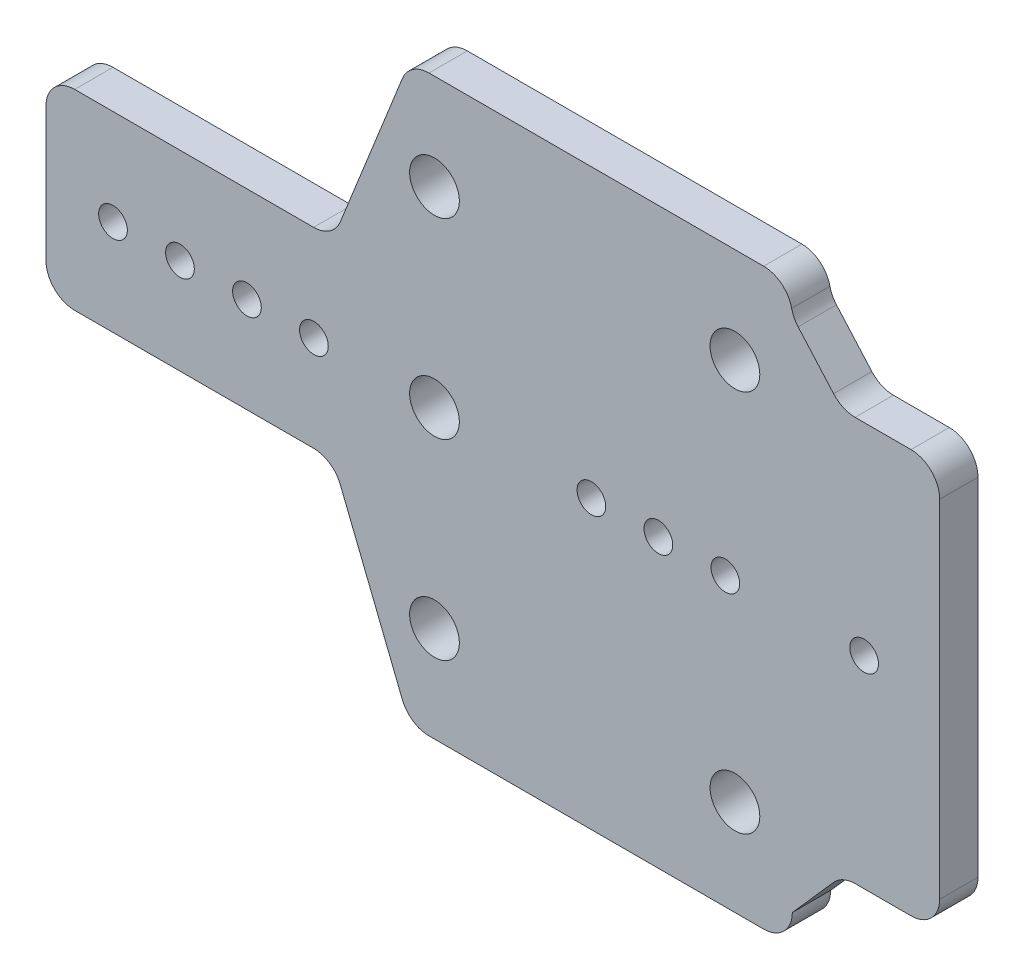
from build123d import *

# Parameters (mm, degrees)
BOSS_EXTRUDE1_DEPTH = 4
FILLET1_R           = 3
SKETCH3_R           = 2.6
CUT_EXTRUDE1_DEPTH  = 4
SKETCH4_R           = 1.5
CUT_EXTRUDE2_DEPTH  = 4
SKETCH5_W           = 15
SKETCH5_H           = 20
BOSS_EXTRUDE2_DEPTH = 4
BOSS_EXTRUDE3_DEPTH = 4
SKETCH7_R           = 1.5
CUT_EXTRUDE3_DEPTH  = 4
BOSS_EXTRUDE4_DEPTH = 4
SKETCH10_R          = 11.5
CUT_EXTRUDE4_DEPTH  = 4
SKETCH14_R          = 1.5
CUT_EXTRUDE5_DEPTH  = 4
FILLET2_R           = 3
SKETCH17_W          = 41.796836064
SKETCH17_H          = 42.2
CUT_EXTRUDE6_DEPTH  = 10
FILLET3_R           = 3


with BuildPart() as part:
    # Sketch1 → Boss-Extrude1 (new body)
    with BuildSketch(Plane.XY):
        Polygon((39, 10), (39, 30), (-1, 30), (-9, 10), (-39, 10), (-39, -10), (-9, -10), (-1, -30), (39, -30), (39, -10), align=None)
    extrude(amount=BOSS_EXTRUDE1_DEPTH)

    # Fillet1
    fillet1_edges = [part.edges().sort_by_distance(p)[0] for p in [
        (39, -30, 2),
        (-1, -30, 2),
        (-9, -10, 2),
        (-39, -10, 2),
        (-39, 10, 2),
        (-9, 10, 2),
        (-1, 30, 2),
        (39, 30, 2),
    ]]
    fillet(fillet1_edges, radius=FILLET1_R)

    # Sketch3 → Cut-Extrude1 (cut)
    with BuildSketch(Plane.XY.offset(4)):
        with Locations((33, 20)):
            Circle(SKETCH3_R)
        with Locations((1.6, 20)):
            Circle(SKETCH3_R)
        with Locations((33, -20)):
            Circle(SKETCH3_R)
        with Locations((1.6, -20)):
            Circle(SKETCH3_R)
        with Locations((1.6, 0)):
            Circle(SKETCH3_R)
    extrude(amount=-CUT_EXTRUDE1_DEPTH, mode=Mode.SUBTRACT)

    # Sketch4 → Cut-Extrude2 (cut)
    with BuildSketch(Plane.XY.offset(4)):
        with Locations((-32, 0)):
            Circle(SKETCH4_R)
        with Locations((-25, 0)):
            Circle(SKETCH4_R)
        with Locations((-18, 0)):
            Circle(SKETCH4_R)
        with Locations((-11, 0)):
            Circle(SKETCH4_R)
        with Locations((32, 0)):
            Circle(SKETCH4_R)
        with Locations((25, 0)):
            Circle(SKETCH4_R)
        with Locations((18, 0)):
            Circle(SKETCH4_R)
    extrude(amount=-CUT_EXTRUDE2_DEPTH, mode=Mode.SUBTRACT)

    # Sketch5 → Boss-Extrude2 (add)
    with BuildSketch(Plane.XY.offset(4)):
        with Locations((46.5, 0)):
            Rectangle(SKETCH5_W, SKETCH5_H)
    extrude(amount=-BOSS_EXTRUDE2_DEPTH)

    # Sketch6 → Boss-Extrude3 (add)
    with BuildSketch(Plane.XY.offset(4)):
        Polygon((39, 10), (54, 10), (39, 27), align=None)
        Polygon((54, -10), (39, -10), (39, -27), align=None)
    extrude(amount=-BOSS_EXTRUDE3_DEPTH)

    # Sketch7 → Cut-Extrude3 (cut)
    with BuildSketch(Plane.XY.offset(4)):
        with Locations((46.5, 0)):
            Circle(SKETCH7_R)
    extrude(amount=-CUT_EXTRUDE3_DEPTH, mode=Mode.SUBTRACT)

    # Sketch8 → Boss-Extrude4 (add)
    with BuildSketch(Plane.XY.offset(4)):
        Polygon((54, -10), (54, -21.1), (96.2, -21.1), (96.2, 21.1), (54, 21.1), (54, 10), align=None)
        Polygon((44.205882353, 21.1), (54, 10), (54, 21.1), align=None)
        Polygon((44.205882353, -21.1), (54, -21.1), (54, -10), align=None)
    extrude(amount=-BOSS_EXTRUDE4_DEPTH)

    # Sketch10 → Cut-Extrude4 (cut)
    with BuildSketch(Plane.XY.offset(4)):
        with Locations((74.8, 0)):
            Circle(SKETCH10_R)
    extrude(amount=-CUT_EXTRUDE4_DEPTH, mode=Mode.SUBTRACT)

    # Sketch14 → Cut-Extrude5 (cut)
    with BuildSketch(Plane.XY.offset(4)):
        with Locations((90.674547238, 15.874547238)):
            Circle(SKETCH14_R)
        with Locations((58.925452762, -15.874547238)):
            Circle(SKETCH14_R)
        with Locations((58.925452762, 15.874547238)):
            Circle(SKETCH14_R)
        with Locations((90.674547238, -15.874547238)):
            Circle(SKETCH14_R)
    extrude(amount=-CUT_EXTRUDE5_DEPTH, mode=Mode.SUBTRACT)

    # Fillet2
    fillet2_edges = [part.edges().sort_by_distance(p)[0] for p in [
        (96.2, -21.1, 2),
        (44.205882353, -21.1, 2),
        (44.205882353, 21.1, 2),
        (96.2, 21.1, 2),
        (39, 27, 2),
    ]]
    fillet(fillet2_edges, radius=FILLET2_R)

    # Sketch17 → Cut-Extrude6 (cut)
    with BuildSketch(Plane.XY.offset(4)):
        with Locations((75.301581968, 0)):
            Rectangle(SKETCH17_W, SKETCH17_H)
    extrude(amount=-CUT_EXTRUDE6_DEPTH, mode=Mode.SUBTRACT)

    # Fillet3
    fillet3_edges = [part.edges().sort_by_distance(p)[0] for p in [
        (54.403163936, -21.1, 2),
        (54.403163936, 21.1, 2),
    ]]
    fillet(fillet3_edges, radius=FILLET3_R)


solid = part.part
